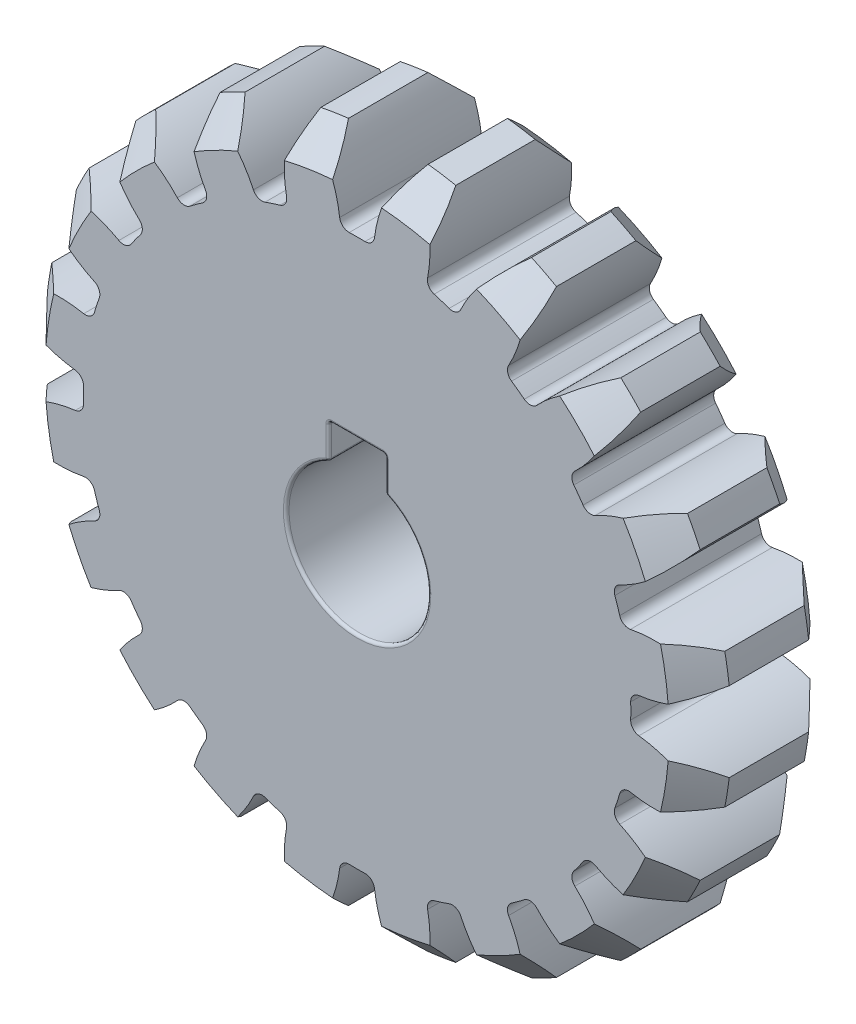
from build123d import *

# Parameters (mm, degrees)
SKETCH1_R                = 24.2
BOSS_EXTRUDE1_DEPTH      = 5
CUT_EXTRUDE1_DEPTH       = 6
FILLET1_R                = 0.66
CHAMFER1_SIZE            = 2.2
CIRPATTERN1_COUNT        = 20
FILLET1_OF_CIRPATTERN1_R = 0.66
CUT_EXTRUDE2_DEPTH       = 11.0000001
FILLET2_R                = 0.2


with BuildPart() as part:
    # Sketch1 → Boss-Extrude1 (new body, symmetric)
    with BuildSketch(Plane.XY):
        Circle(SKETCH1_R)
    extrude(amount=BOSS_EXTRUDE1_DEPTH, both=True)

    # Sketch2 → Cut-Extrude1 (cut, symmetric)
    with BuildSketch(Plane.XY):
        with BuildLine():
            ThreePointArc((2.806060396, 24.03676403), (1.665729243, 21.761247794), (1.171675149, 19.264401816))
            ThreePointArc((1.171675149, 19.264401816), (0, 19.3), (-1.171675149, 19.264401816))
            ThreePointArc((-1.171675149, 19.264401816), (-1.665729243, 21.761247794), (-2.806060396, 24.03676403))
            ThreePointArc((-2.806060396, 24.03676403), (0, 24.2), (2.806060396, 24.03676403))
        make_face()
    cut_extrude1 = extrude(amount=CUT_EXTRUDE1_DEPTH, both=True, mode=Mode.SUBTRACT)

    # Fillet1
    fillet1_edges = [part.edges().sort_by_distance(p)[0] for p in [
        (1.171675149, 19.264401816, 0),
        (-1.171675149, 19.264401816, 0),
    ]]
    fillet(fillet1_edges, radius=FILLET1_R)

    # Chamfer1
    chamfer1_edges = [part.edges().sort_by_distance(p)[0] for p in [
        (0, -24.2, -5),
        (0, -24.2, 5),
    ]]
    chamfer(chamfer1_edges, length=CHAMFER1_SIZE)

    # CirPattern1: Cut-Extrude1 ×20 about axis
    cirpattern1_axis = Axis((0, 0, 0), (0, 0, 1))
    for i in range(1, CIRPATTERN1_COUNT):
        add(cut_extrude1.rotate(cirpattern1_axis, i * 360 / CIRPATTERN1_COUNT), mode=Mode.SUBTRACT)

    # Fillet1 of CirPattern1
    fillet1_of_cirpattern1_edges = [part.edges().sort_by_distance(p)[0] for p in [
        (-4.838698263, 18.683602413, 0),
        (-7.067356833, 17.959467347, 0),
        (-10.375426175, 16.273921829, 0),
        (-12.271236389, 14.896535083, 0),
        (-14.896535083, 12.271236389, 0),
        (-16.273921829, 10.375426175, 0),
        (-17.959467347, 7.067356833, 0),
        (-18.683602413, 4.838698263, 0),
        (-19.264401816, 1.171675149, 0),
        (-19.264401816, -1.171675149, 0),
        (-18.683602413, -4.838698263, 0),
        (-17.959467347, -7.067356833, 0),
        (-16.273921829, -10.375426175, 0),
        (-14.896535083, -12.271236389, 0),
        (-12.271236389, -14.896535083, 0),
        (-10.375426175, -16.273921829, 0),
        (-7.067356833, -17.959467347, 0),
        (-4.838698263, -18.683602413, 0),
        (-1.171675149, -19.264401816, 0),
        (1.171675149, -19.264401816, 0),
        (4.838698263, -18.683602413, 0),
        (7.067356833, -17.959467347, 0),
        (10.375426175, -16.273921829, 0),
        (12.271236389, -14.896535083, 0),
        (14.896535083, -12.271236389, 0),
        (16.273921829, -10.375426175, 0),
        (17.959467347, -7.067356833, 0),
        (18.683602413, -4.838698263, 0),
        (19.264401816, -1.171675149, 0),
        (19.264401816, 1.171675149, 0),
        (18.683602413, 4.838698263, 0),
        (17.959467347, 7.067356833, 0),
        (16.273921829, 10.375426175, 0),
        (14.896535083, 12.271236389, 0),
        (12.271236389, 14.896535083, 0),
        (10.375426175, 16.273921829, 0),
        (7.067356833, 17.959467347, 0),
        (4.838698263, 18.683602413, 0),
    ]]
    fillet(fillet1_of_cirpattern1_edges, radius=FILLET1_OF_CIRPATTERN1_R)

    # Sketch3 → Cut-Extrude2 (cut, through all)
    with BuildSketch(Plane.XY.offset(5)):
        with BuildLine():
            Line((-2, 4.582575695), (-2, 7))
            Line((-2, 7), (2, 7))
            Line((2, 7), (2, 4.582575695))
            ThreePointArc((2, 4.582575695), (0, -5), (-2, 4.582575695))
        make_face()
    extrude(amount=-CUT_EXTRUDE2_DEPTH, mode=Mode.SUBTRACT)

    # Fillet2
    fillet2_edges = [part.edges().sort_by_distance(p)[0] for p in [
        (0, -5, -5),
        (2, 4.582575695, 0),
        (-2, 5.791287847, -5),
        (-2, 4.582575695, 0),
        (0, 7, -5),
        (-2, 7, 0),
        (2, 5.791287847, -5),
        (2, 7, 0),
        (0, -5, 5),
        (2, 5.791287847, 5),
        (0, 7, 5),
        (-2, 5.791287847, 5),
    ]]
    fillet(fillet2_edges, radius=FILLET2_R)


solid = part.part
